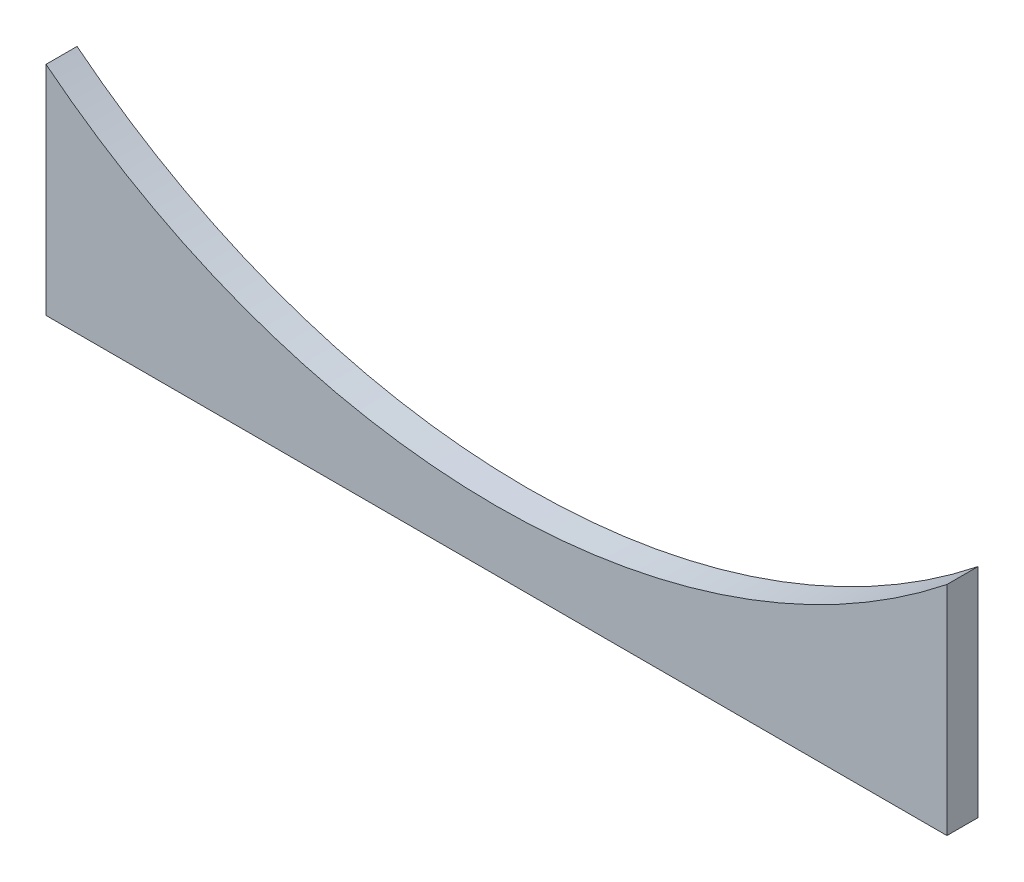
from build123d import *

# Parameters (mm, degrees)
SKETCH1_W               = 184.15
SKETCH1_H               = 44.45
BOSS_EXTRUDE1_DEPTH     = 6.35
CUT_EXTRUDE1_DEPTH      = 1
CUT_EXTRUDE1_DEPTH_BACK = 7.35


with BuildPart() as part:
    # Sketch1 → Boss-Extrude1 (new body)
    with BuildSketch(Plane.XY):
        Rectangle(SKETCH1_W, SKETCH1_H)
    extrude(amount=BOSS_EXTRUDE1_DEPTH)

    # Sketch2 → Cut-Extrude1 (cut, two sides)
    with BuildSketch(Plane.XY.offset(6.35)) as cut_extrude1_sk:
        with BuildLine():
            Line((-396.377116698, 264.352797226), (-92.075, 22.225))
            ThreePointArc((-92.075, 22.225), (0, -9.936822044), (92.075, 22.225))
            Line((92.075, 22.225), (396.377116698, 264.352797226))
            Line((396.377116698, 264.352797226), (396.377116698, 1042.107638847))
            Line((396.377116698, 1042.107638847), (-396.377116698, 1042.107638847))
            Line((-396.377116698, 1042.107638847), (-396.377116698, 264.352797226))
        make_face()
    extrude(amount=CUT_EXTRUDE1_DEPTH, mode=Mode.SUBTRACT)
    extrude(cut_extrude1_sk.sketch, amount=-CUT_EXTRUDE1_DEPTH_BACK, mode=Mode.SUBTRACT)


solid = part.part
